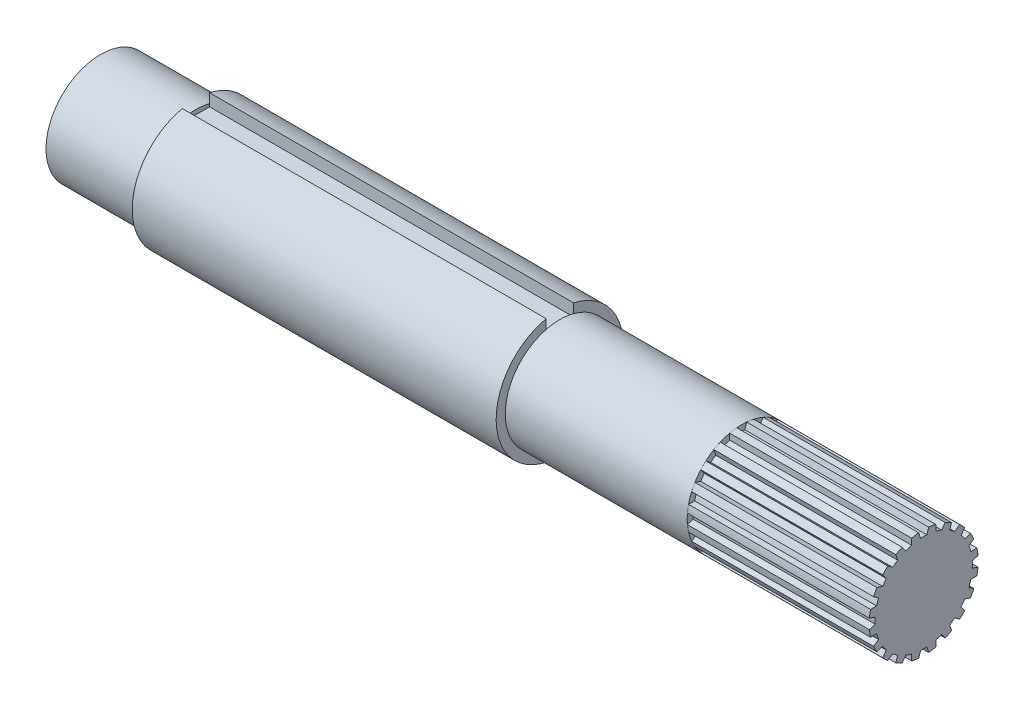
from build123d import *

# Parameters (mm, degrees)
SKETCH1_R           = 9.525
BOSS_EXTRUDE1_DEPTH = 63.5
SKETCH2_OUTSIDE_W   = 34.846
SKETCH2_OUTSIDE_H   = 34.846
CUT_EXTRUDE1_DEPTH  = 31.75
SKETCH3_R           = 11.1125
BOSS_EXTRUDE2_DEPTH = 63.5
SKETCH4_R           = 9.525
BOSS_EXTRUDE3_DEPTH = 16.637
CUT_EXTRUDE2_DEPTH  = 63.5


with BuildPart() as part:
    # Sketch1 → Boss-Extrude1 (new body)
    with BuildSketch(Plane(origin=(0, 0, 0), x_dir=(0, 0, -1), z_dir=(1, 0, 0))):
        Circle(SKETCH1_R)
    extrude(amount=BOSS_EXTRUDE1_DEPTH)

    # Sketch2 outside → Cut-Extrude1 (cut)
    with BuildSketch(Plane(origin=(63.5, 0, 0), x_dir=(0, 0, -1), z_dir=(1, 0, 0))):
        Rectangle(SKETCH2_OUTSIDE_W, SKETCH2_OUTSIDE_H)
        with BuildLine():
            Line((-2.10185, -8.219105519), (-2.10185, -9.277180491))
            ThreePointArc((-2.10185, -9.277180491), (-1.488051562, -9.395187802), (-0.867828293, -9.472630329))
            Line((-0.867828293, -9.472630329), (-0.540865145, -8.466341232))
            ThreePointArc((-0.540865145, -8.466341232), (0, -8.4836), (0.540865145, -8.466341232))
            Line((0.540865145, -8.466341232), (0.867828293, -9.472630329))
            ThreePointArc((0.867828293, -9.472630329), (1.488051562, -9.395187802), (2.10185, -9.277180491))
            Line((2.10185, -9.277180491), (2.10185, -8.219105519))
            ThreePointArc((2.10185, -8.219105519), (2.621576573, -8.068383062), (3.130636642, -7.884832476))
            Line((3.130636642, -7.884832476), (3.752557506, -8.74083311))
            ThreePointArc((3.752557506, -8.74083311), (4.318493831, -8.47552136), (4.86578457, -8.173615589))
            Line((4.86578457, -8.173615589), (4.538821423, -7.167326493))
            ThreePointArc((4.538821423, -7.167326493), (4.986534966, -6.863376573), (5.413959611, -6.531501381))
            Line((5.413959611, -6.531501381), (6.269960245, -7.153422245))
            ThreePointArc((6.269960245, -7.153422245), (6.726211835, -6.726211835), (7.153422245, -6.269960245))
            Line((7.153422245, -6.269960245), (6.531501381, -5.413959611))
            ThreePointArc((6.531501381, -5.413959611), (6.863376573, -4.986534966), (7.167326493, -4.538821423))
            Line((7.167326493, -4.538821423), (8.173615589, -4.86578457))
            ThreePointArc((8.173615589, -4.86578457), (8.47552136, -4.318493831), (8.74083311, -3.752557506))
            Line((8.74083311, -3.752557506), (7.884832476, -3.130636642))
            ThreePointArc((7.884832476, -3.130636642), (8.068383062, -2.621576573), (8.219105519, -2.10185))
            Line((8.219105519, -2.10185), (9.277180491, -2.10185))
            ThreePointArc((9.277180491, -2.10185), (9.395187802, -1.488051562), (9.472630329, -0.867828293))
            Line((9.472630329, -0.867828293), (8.466341232, -0.540865145))
            ThreePointArc((8.466341232, -0.540865145), (8.4836, 0), (8.466341232, 0.540865145))
            Line((8.466341232, 0.540865145), (9.472630329, 0.867828293))
            ThreePointArc((9.472630329, 0.867828293), (9.395187802, 1.488051562), (9.277180491, 2.10185))
            Line((9.277180491, 2.10185), (8.219105519, 2.10185))
            ThreePointArc((8.219105519, 2.10185), (8.068383062, 2.621576573), (7.884832476, 3.130636642))
            Line((7.884832476, 3.130636642), (8.74083311, 3.752557506))
            ThreePointArc((8.74083311, 3.752557506), (8.47552136, 4.318493831), (8.173615589, 4.86578457))
            Line((8.173615589, 4.86578457), (7.167326493, 4.538821423))
            ThreePointArc((7.167326493, 4.538821423), (6.863376573, 4.986534966), (6.531501381, 5.413959611))
            Line((6.531501381, 5.413959611), (7.153422245, 6.269960245))
            ThreePointArc((7.153422245, 6.269960245), (6.726211835, 6.726211835), (6.269960245, 7.153422245))
            Line((6.269960245, 7.153422245), (5.413959611, 6.531501381))
            ThreePointArc((5.413959611, 6.531501381), (4.986534966, 6.863376573), (4.538821423, 7.167326493))
            Line((4.538821423, 7.167326493), (4.86578457, 8.173615589))
            ThreePointArc((4.86578457, 8.173615589), (4.318493831, 8.47552136), (3.752557506, 8.74083311))
            Line((3.752557506, 8.74083311), (3.130636642, 7.884832476))
            ThreePointArc((3.130636642, 7.884832476), (2.621576573, 8.068383062), (2.10185, 8.219105519))
            Line((2.10185, 8.219105519), (2.10185, 9.277180491))
            ThreePointArc((2.10185, 9.277180491), (1.488051562, 9.395187802), (0.867828293, 9.472630329))
            Line((0.867828293, 9.472630329), (0.540865145, 8.466341232))
            ThreePointArc((0.540865145, 8.466341232), (0, 8.4836), (-0.540865145, 8.466341232))
            Line((-0.540865145, 8.466341232), (-0.867828293, 9.472630329))
            ThreePointArc((-0.867828293, 9.472630329), (-1.488051562, 9.395187802), (-2.10185, 9.277180491))
            Line((-2.10185, 9.277180491), (-2.10185, 8.219105519))
            ThreePointArc((-2.10185, 8.219105519), (-2.621576573, 8.068383062), (-3.130636642, 7.884832476))
            Line((-3.130636642, 7.884832476), (-3.752557506, 8.74083311))
            ThreePointArc((-3.752557506, 8.74083311), (-4.318493831, 8.47552136), (-4.86578457, 8.173615589))
            Line((-4.86578457, 8.173615589), (-4.538821423, 7.167326493))
            ThreePointArc((-4.538821423, 7.167326493), (-4.986534966, 6.863376573), (-5.413959611, 6.531501381))
            Line((-5.413959611, 6.531501381), (-6.269960245, 7.153422245))
            ThreePointArc((-6.269960245, 7.153422245), (-6.726211835, 6.726211835), (-7.153422245, 6.269960245))
            Line((-7.153422245, 6.269960245), (-6.531501381, 5.413959611))
            ThreePointArc((-6.531501381, 5.413959611), (-6.863376573, 4.986534966), (-7.167326493, 4.538821423))
            Line((-7.167326493, 4.538821423), (-8.173615589, 4.86578457))
            ThreePointArc((-8.173615589, 4.86578457), (-8.47552136, 4.318493831), (-8.74083311, 3.752557506))
            Line((-8.74083311, 3.752557506), (-7.884832476, 3.130636642))
            ThreePointArc((-7.884832476, 3.130636642), (-8.068383062, 2.621576573), (-8.219105519, 2.10185))
            Line((-8.219105519, 2.10185), (-9.277180491, 2.10185))
            ThreePointArc((-9.277180491, 2.10185), (-9.395187802, 1.488051562), (-9.472630329, 0.867828293))
            Line((-9.472630329, 0.867828293), (-8.466341232, 0.540865145))
            ThreePointArc((-8.466341232, 0.540865145), (-8.4836, 0), (-8.466341232, -0.540865145))
            Line((-8.466341232, -0.540865145), (-9.472630329, -0.867828293))
            ThreePointArc((-9.472630329, -0.867828293), (-9.395187802, -1.488051562), (-9.277180491, -2.10185))
            Line((-9.277180491, -2.10185), (-8.219105519, -2.10185))
            ThreePointArc((-8.219105519, -2.10185), (-8.068383062, -2.621576573), (-7.884832476, -3.130636642))
            Line((-7.884832476, -3.130636642), (-8.74083311, -3.752557506))
            ThreePointArc((-8.74083311, -3.752557506), (-8.47552136, -4.318493831), (-8.173615589, -4.86578457))
            Line((-8.173615589, -4.86578457), (-7.167326493, -4.538821423))
            ThreePointArc((-7.167326493, -4.538821423), (-6.863376573, -4.986534966), (-6.531501381, -5.413959611))
            Line((-6.531501381, -5.413959611), (-7.153422245, -6.269960245))
            ThreePointArc((-7.153422245, -6.269960245), (-6.726211835, -6.726211835), (-6.269960245, -7.153422245))
            Line((-6.269960245, -7.153422245), (-5.413959611, -6.531501381))
            ThreePointArc((-5.413959611, -6.531501381), (-4.986534966, -6.863376573), (-4.538821423, -7.167326493))
            Line((-4.538821423, -7.167326493), (-4.86578457, -8.173615589))
            ThreePointArc((-4.86578457, -8.173615589), (-4.318493831, -8.47552136), (-3.752557506, -8.74083311))
            Line((-3.752557506, -8.74083311), (-3.130636642, -7.884832476))
            ThreePointArc((-3.130636642, -7.884832476), (-2.621576573, -8.068383062), (-2.10185, -8.219105519))
        make_face(mode=Mode.SUBTRACT)
    extrude(amount=-CUT_EXTRUDE1_DEPTH, mode=Mode.SUBTRACT)

    # Sketch3 → Boss-Extrude2 (add)
    with BuildSketch(Plane.ZY):
        Circle(SKETCH3_R)
    extrude(amount=BOSS_EXTRUDE2_DEPTH)

    # Sketch4 → Boss-Extrude3 (add)
    with BuildSketch(Plane.ZY.offset(63.5)):
        Circle(SKETCH4_R)
    extrude(amount=BOSS_EXTRUDE3_DEPTH)

    # Sketch5 → Cut-Extrude2 (cut)
    with BuildSketch(Plane.ZY.offset(63.5)):
        with BuildLine():
            Line((0, 8.7249), (2.3876, 8.7249))
            Line((2.3876, 8.7249), (2.3876, 10.852972979))
            ThreePointArc((2.3876, 10.852972979), (0, 11.1125), (-2.3876, 10.852972979))
            Line((-2.3876, 10.852972979), (-2.3876, 8.7249))
            Line((-2.3876, 8.7249), (0, 8.7249))
        make_face()
    extrude(amount=-CUT_EXTRUDE2_DEPTH, mode=Mode.SUBTRACT)


solid = part.part
